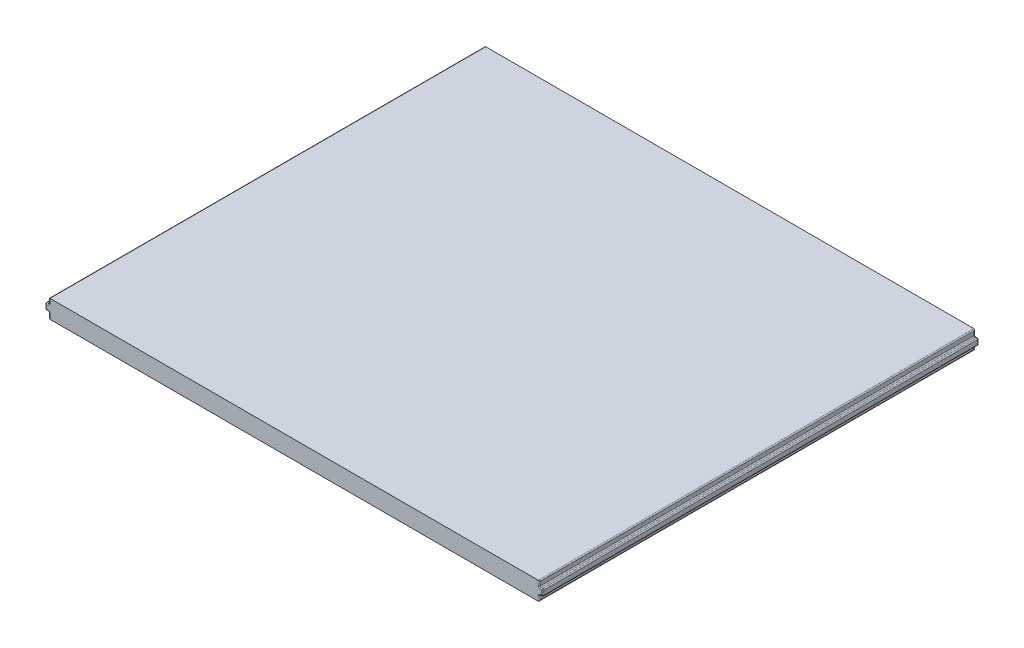
from build123d import *

# Parameters (mm, degrees)
SKETCH1_W           = 135
SKETCH1_H           = 120
BOSS_EXTRUDE1_DEPTH = 5
SKETCH2_W           = 120
SKETCH2_H           = 1.75
BOSS_EXTRUDE2_DEPTH = 1
FILLET1_R           = 0.3


with BuildPart() as part:
    # Sketch1 → Boss-Extrude1 (new body)
    with BuildSketch(Plane(origin=(0, 0, 0), x_dir=(1, 0, 0), z_dir=(0, 1, 0))):
        with Locations((1501.472148541, 1006.446286472)):
            Rectangle(SKETCH1_W, SKETCH1_H)
    extrude(amount=BOSS_EXTRUDE1_DEPTH)

    # Sketch2 → Boss-Extrude2 (add)
    with BuildSketch(Plane(origin=(1568.972148541, 0, 0), x_dir=(0, 0, -1), z_dir=(1, 0, 0))):
        with Locations((1006.446286472, 2.525)):
            Rectangle(SKETCH2_W, SKETCH2_H)
    boss_extrude2 = extrude(amount=BOSS_EXTRUDE2_DEPTH)

    # Mirror1: Boss-Extrude2 across plane
    add(boss_extrude2.mirror(Plane.ZY.offset(-1501.472148541)))

    # Fillet1
    fillet1_edges = [part.edges().sort_by_distance(p)[0] for p in [
        (1568.972148541, 5, -1006.446286472),
        (1568.972148541, 0.825, -1066.446286472),
        (1568.972148541, 0.825, -946.446286472),
        (1569.472148541, 3.4, -946.446286472),
        (1568.972148541, 1.65, -1006.446286472),
        (1569.472148541, 1.65, -946.446286472),
        (1569.472148541, 1.65, -1066.446286472),
        (1568.972148541, 3.4, -1006.446286472),
        (1569.472148541, 3.4, -1066.446286472),
        (1569.972148541, 2.525, -946.446286472),
        (1569.972148541, 1.65, -1006.446286472),
        (1569.972148541, 2.525, -1066.446286472),
        (1569.972148541, 3.4, -1006.446286472),
        (1433.972148541, 0.825, -946.446286472),
        (1433.972148541, 0.825, -1066.446286472),
        (1432.972148541, 2.525, -946.446286472),
        (1433.472148541, 1.65, -946.446286472),
        (1432.972148541, 3.4, -1006.446286472),
        (1433.472148541, 3.4, -946.446286472),
        (1432.972148541, 2.525, -1066.446286472),
        (1433.472148541, 3.4, -1066.446286472),
        (1432.972148541, 1.65, -1006.446286472),
        (1433.472148541, 1.65, -1066.446286472),
        (1433.972148541, 1.65, -1006.446286472),
        (1433.972148541, 3.4, -1006.446286472),
        (1433.972148541, 5, -1006.446286472),
        (1568.972148541, 0, -1006.446286472),
        (1433.972148541, 0, -1006.446286472),
        (1433.972148541, 4.2, -1066.446286472),
        (1568.972148541, 4.2, -1066.446286472),
        (1568.972148541, 4.2, -946.446286472),
        (1433.972148541, 4.2, -946.446286472),
    ]]
    fillet(fillet1_edges, radius=FILLET1_R)


solid = part.part
